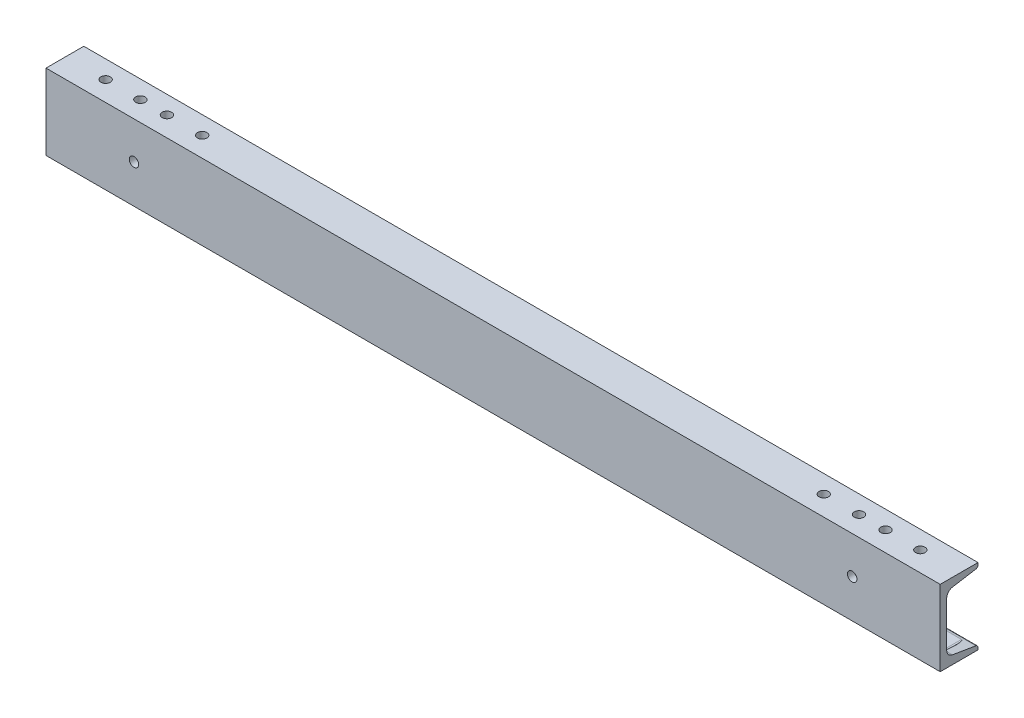
from build123d import *

# Parameters (mm, degrees)
STRUCTURAL_MEMBER1_DEPTH = 900
SKETCH12_R               = 4.7625
CUT_EXTRUDE1_DEPTH       = 454.210052427
CUT_EXTRUDE2_DEPTH       = 40
SKETCH16_R               = 4.7625
CUT_EXTRUDE3_DEPTH       = 454.210052526
SKETCH17_R               = 4.7625
CUT_EXTRUDE4_DEPTH       = 454.210052526


with BuildPart() as part:
    # Sketch11 → Structural Member1 (new body)
    with BuildSketch(Plane(origin=(-450, 0, 0), x_dir=(0, 0, -1), z_dir=(1, 0, 0))):
        with BuildLine():
            Line((0, -38.1), (0, 38.1))
            Line((0, 38.1), (38.0492, 38.1))
            Line((38.0492, 38.1), (38.0492, 35.942335136))
            ThreePointArc((38.0492, 35.942335136), (37.447280466, 34.300554363), (35.926803066, 33.436899509))
            Line((35.926803066, 33.436899509), (12.283671721, 29.496090157))
            ThreePointArc((12.283671721, 29.496090157), (8.178382741, 27.164222052), (6.5532, 22.731413966))
            Line((6.5532, 22.731413966), (6.5532, -22.731413966))
            ThreePointArc((6.5532, -22.731413966), (8.178382741, -27.164222052), (12.283671721, -29.496090157))
            Line((12.283671721, -29.496090157), (35.926803066, -33.436899509))
            ThreePointArc((35.926803066, -33.436899509), (37.447280466, -34.300554363), (38.0492, -35.942335136))
            Line((38.0492, -35.942335136), (38.0492, -38.1))
            Line((38.0492, -38.1), (0, -38.1))
        make_face()
    extrude(amount=STRUCTURAL_MEMBER1_DEPTH)

    # Sketch12 → Cut-Extrude1 (cut, through all)
    with BuildSketch(Plane(origin=(0, 0, 0), x_dir=(1, 0, 0), z_dir=(0, 1, 0))):
        with Locations(Location((-425, 20, 0), (0, 0, 270))):
            Circle(SKETCH12_R)
        with Locations(Location((425, 20, 0), (0, 0, 270))):
            Circle(SKETCH12_R)
    extrude(amount=-CUT_EXTRUDE1_DEPTH, mode=Mode.SUBTRACT)

    # Sketch15 → Cut-Extrude2 (cut)
    with BuildSketch(Plane(origin=(0, 0, -6.5532), x_dir=(-1, 0, 0), z_dir=(0, 0, -1))):
        with BuildLine():
            Line((-412.5, -33.1), (-437.5, -33.1))
            ThreePointArc((-437.5, -33.1), (-442.5, -28.1), (-437.5, -23.1))
            Line((-437.5, -23.1), (-412.5, -23.1))
            ThreePointArc((-412.5, -23.1), (-407.5, -28.1), (-412.5, -33.1))
        make_face()
        with BuildLine():
            Line((412.5, -33.1), (437.5, -33.1))
            ThreePointArc((437.5, -33.1), (442.5, -28.1), (437.5, -23.1))
            Line((437.5, -23.1), (412.5, -23.1))
            ThreePointArc((412.5, -23.1), (407.5, -28.1), (412.5, -33.1))
        make_face()
    extrude(amount=CUT_EXTRUDE2_DEPTH, mode=Mode.SUBTRACT)

    # Sketch16 → Cut-Extrude3 (cut, through all)
    with BuildSketch(Plane(origin=(0, 0, 0), x_dir=(1, 0, 0), z_dir=(0, 1, 0))):
        with Locations(Location((-348.3, 20, 0), (0, 0, 270))):
            Circle(SKETCH16_R)
        with Locations(Location((-312.8, 20, 0), (0, 0, 270))):
            Circle(SKETCH16_R)
        with Locations(Location((312.8, 20, 0), (0, 0, 90))):
            Circle(SKETCH16_R)
        with Locations(Location((348.3, 20, 0), (0, 0, 90))):
            Circle(SKETCH16_R)
        with Locations(Location((-375, 20, 0), (0, 0, 270))):
            Circle(SKETCH16_R)
        with Locations(Location((-410, 20, 0), (0, 0, 270))):
            Circle(SKETCH16_R)
        with Locations(Location((375, 20, 0), (0, 0, 90))):
            Circle(SKETCH16_R)
        with Locations(Location((410, 20, 0), (0, 0, 90))):
            Circle(SKETCH16_R)
    extrude(amount=CUT_EXTRUDE3_DEPTH, mode=Mode.SUBTRACT)

    # Sketch17 → Cut-Extrude4 (cut, through all)
    with BuildSketch(Plane.XY):
        with Locations((-361.4375, 0.6)):
            Circle(SKETCH17_R)
        with Locations((361.4375, 0.6)):
            Circle(SKETCH17_R)
    extrude(amount=-CUT_EXTRUDE4_DEPTH, mode=Mode.SUBTRACT)


solid = part.part
